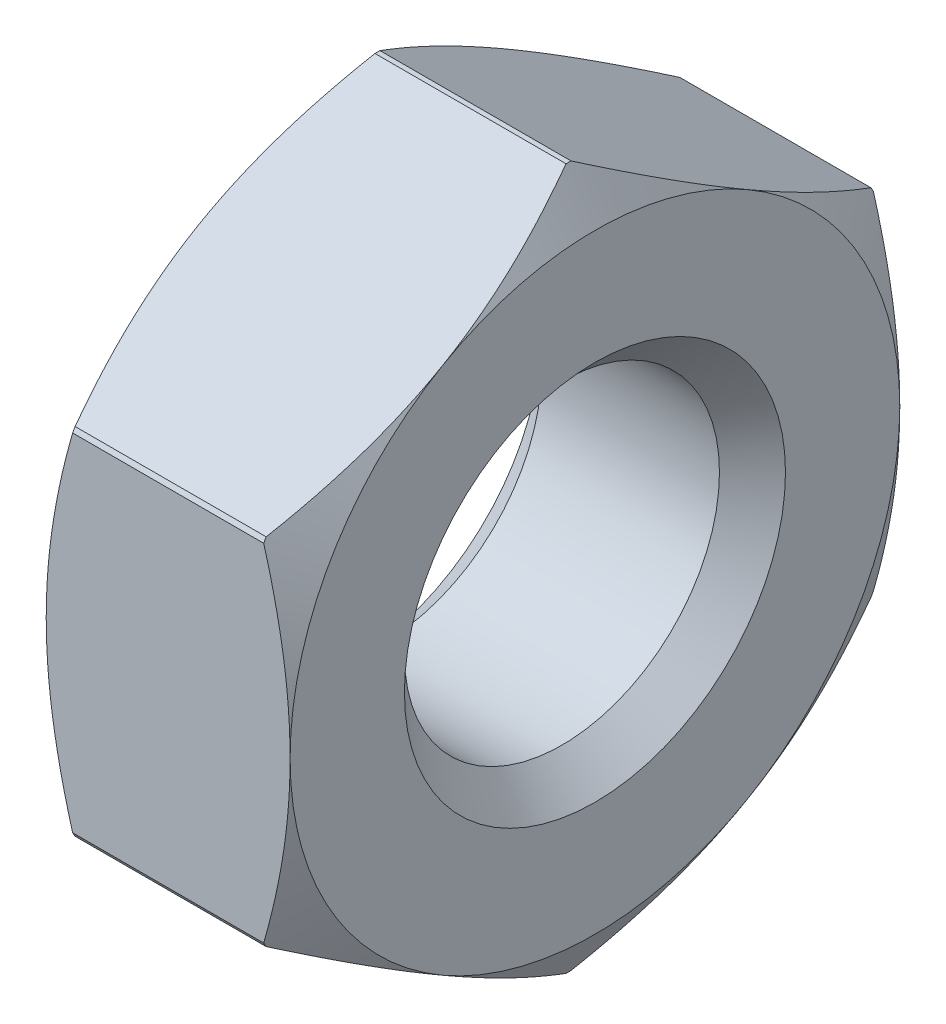
from build123d import *

# Parameters (mm, degrees)
CUT_EXTRUDE1_DEPTH      = 1.6
CUT_EXTRUDE1_DEPTH_BACK = 1.6
SKETCH3_W               = 16
SKETCH3_H               = 16


with BuildPart() as part:
    # Sketch1 → Revolve1 (revolve)
    with BuildSketch(Plane.XY):
        Polygon((-1.6, 0), (-1.6, 4), (-1.253589838, 4.6), (1.253589838, 4.6), (1.6, 4), (1.6, 0), align=None)
    revolve(axis=Axis((1.6, 0, 0), (-1, 0, 0)))

    # Sketch2 → Cut-Revolve1 (revolve, cut)
    with BuildSketch(Plane.XY):
        Polygon((-1.6, 0), (-1.6, 2.5), (-1.167, 2.067), (1.167, 2.067), (1.6, 2.5), (1.6, 0), align=None)
    revolve(axis=Axis((1.6, 0, 0), (-1, 0, 0)), mode=Mode.SUBTRACT)

    # Sketch3 → Cut-Extrude1 (cut, two sides: drawn at the far end of the back side and taken through both)
    with BuildSketch(Plane(origin=(0, 0, 0), x_dir=(0, 0, -1), z_dir=(1, 0, 0)).offset(-CUT_EXTRUDE1_DEPTH_BACK)):
        Rectangle(SKETCH3_W, SKETCH3_H)
        Polygon((-4, 2.309401077), (-4, -2.309401077), (0, -4.618802154), (4, -2.309401077), (4, 2.309401077), (0, 4.618802154), align=None, mode=Mode.SUBTRACT)
    extrude(amount=CUT_EXTRUDE1_DEPTH + CUT_EXTRUDE1_DEPTH_BACK, mode=Mode.SUBTRACT)


solid = part.part
